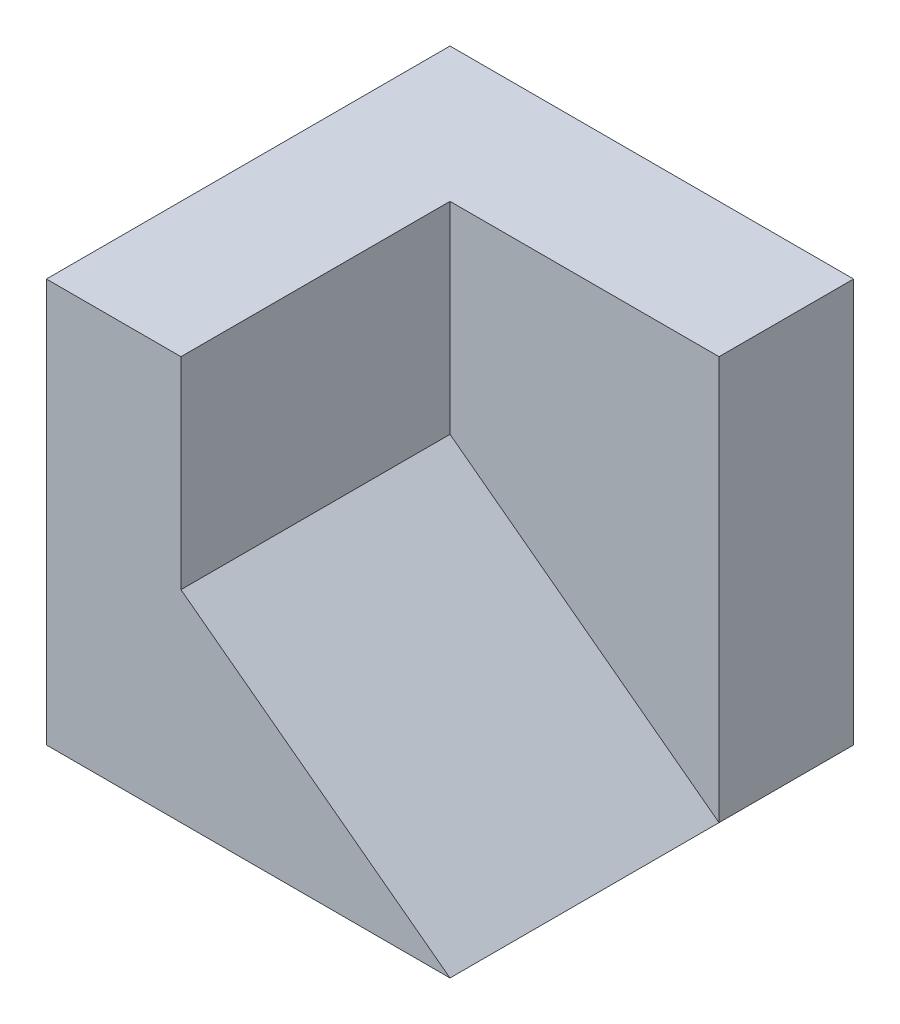
from build123d import *

# Parameters (mm, degrees)
CROQUIS1_W              = 60
CROQUIS1_H              = 60
SALIENTE_EXTRUIR1_DEPTH = 60
CROQUIS2_W              = 40
CROQUIS2_H              = 40
CORTAR_EXTRUIR1_DEPTH   = 30
CORTAR_EXTRUIR2_DEPTH   = 40


with BuildPart() as part:
    # Croquis1 → Saliente-Extruir1 (new body)
    with BuildSketch(Plane(origin=(0, 0, 0), x_dir=(1, 0, 0), z_dir=(0, 1, 0))):
        with Locations((30, -30)):
            Rectangle(CROQUIS1_W, CROQUIS1_H)
    extrude(amount=SALIENTE_EXTRUIR1_DEPTH)

    # Croquis2 → Cortar-Extruir1 (cut)
    with BuildSketch(Plane(origin=(0, 60, 0), x_dir=(1, 0, 0), z_dir=(0, 1, 0))):
        with Locations((40, -40)):
            Rectangle(CROQUIS2_W, CROQUIS2_H)
    extrude(amount=-CORTAR_EXTRUIR1_DEPTH, mode=Mode.SUBTRACT)

    # Croquis3 → Cortar-Extruir2 (cut)
    with BuildSketch(Plane.XY.offset(60)):
        Polygon((20, 30), (60, 30), (60, 0), align=None)
    extrude(amount=-CORTAR_EXTRUIR2_DEPTH, mode=Mode.SUBTRACT)


solid = part.part
